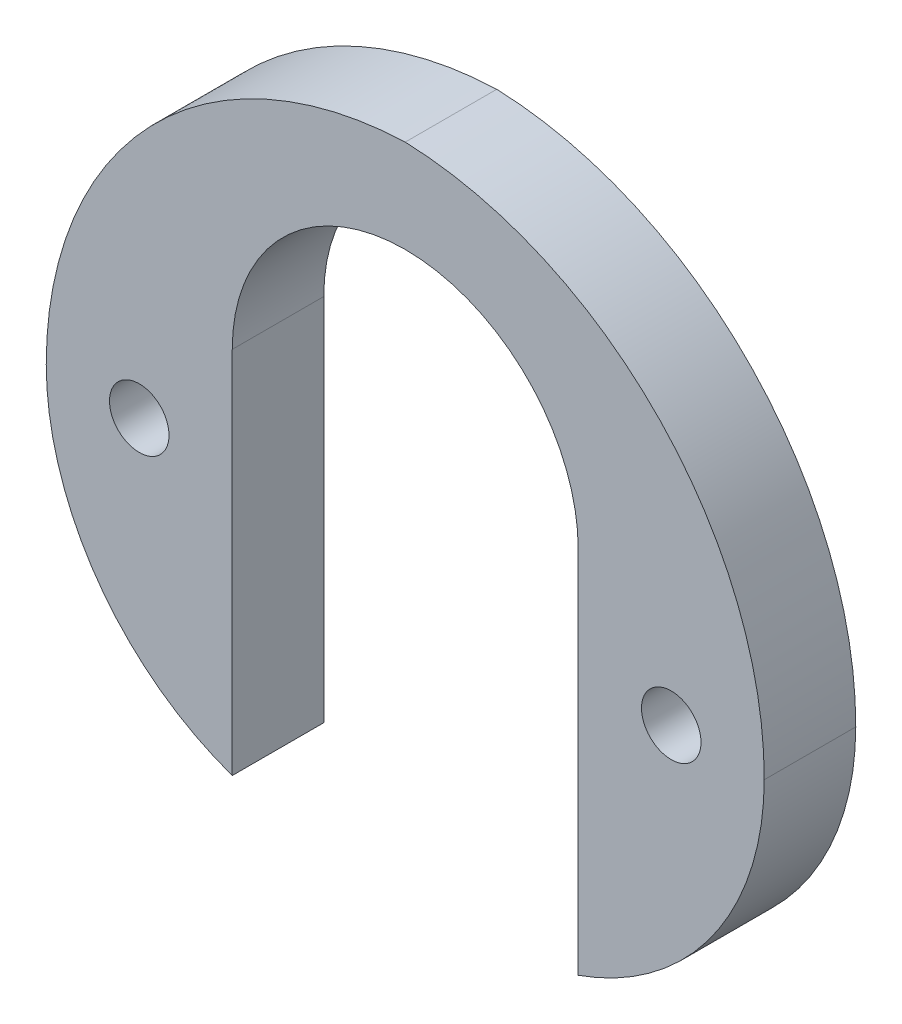
from build123d import *

# Parameters (mm, degrees)
CROQUIS1_R              = 1.016
SALIENTE_EXTRUIR1_DEPTH = 3.1242


with BuildPart() as part:
    # Croquis1 → Saliente-Extruir1 (new body)
    with BuildSketch(Plane.XY):
        with BuildLine():
            Line((0, 9.525), (-2.7305, 9.525))
            ThreePointArc((-2.7305, 9.525), (-9.465692091, 6.735192091), (-12.2555, 0))
            ThreePointArc((-12.2555, 0), (-10.507629933, -5.499261314), (-5.9055, -8.980256121))
            Line((-5.9055, -8.980256121), (-5.9055, -3.6195))
            Line((-5.9055, -3.6195), (-5.9055, 3.6195))
            ThreePointArc((-5.9055, 3.6195), (-4.175819096, 7.795319096), (0, 9.525))
        make_face()
        with Locations((-9.0805, 0)):
            Circle(CROQUIS1_R, mode=Mode.SUBTRACT)
        with BuildLine():
            ThreePointArc((-12.2555, 0), (-9.465692091, 6.735192091), (-2.7305, 9.525))
            Line((-2.7305, 9.525), (0, 9.525))
            Line((0, 9.525), (2.7305, 9.525))
            ThreePointArc((2.7305, 9.525), (9.473939825, 6.726934244), (12.255471398, -0.023342399))
            ThreePointArc((12.255471398, -0.023342399), (8.702367859, 8.818284916), (0, 12.7))
            ThreePointArc((0, 12.7), (-8.691999868, 8.824501123), (-12.2555, 0))
        make_face()
        with BuildLine():
            Line((2.7305, 9.525), (0, 9.525))
            ThreePointArc((0, 9.525), (4.175819096, 7.795319096), (5.9055, 3.6195))
            Line((5.9055, 3.6195), (5.9055, -3.6195))
            Line((5.9055, -3.6195), (5.9055, -8.980256121))
            ThreePointArc((5.9055, -8.980256121), (10.50088572, -5.508786688), (12.255471398, -0.023342399))
            ThreePointArc((12.255471398, -0.023342399), (9.473939825, 6.726934244), (2.7305, 9.525))
        make_face()
        with Locations((9.0805, 0)):
            Circle(CROQUIS1_R, mode=Mode.SUBTRACT)
    extrude(amount=SALIENTE_EXTRUIR1_DEPTH)


solid = part.part
